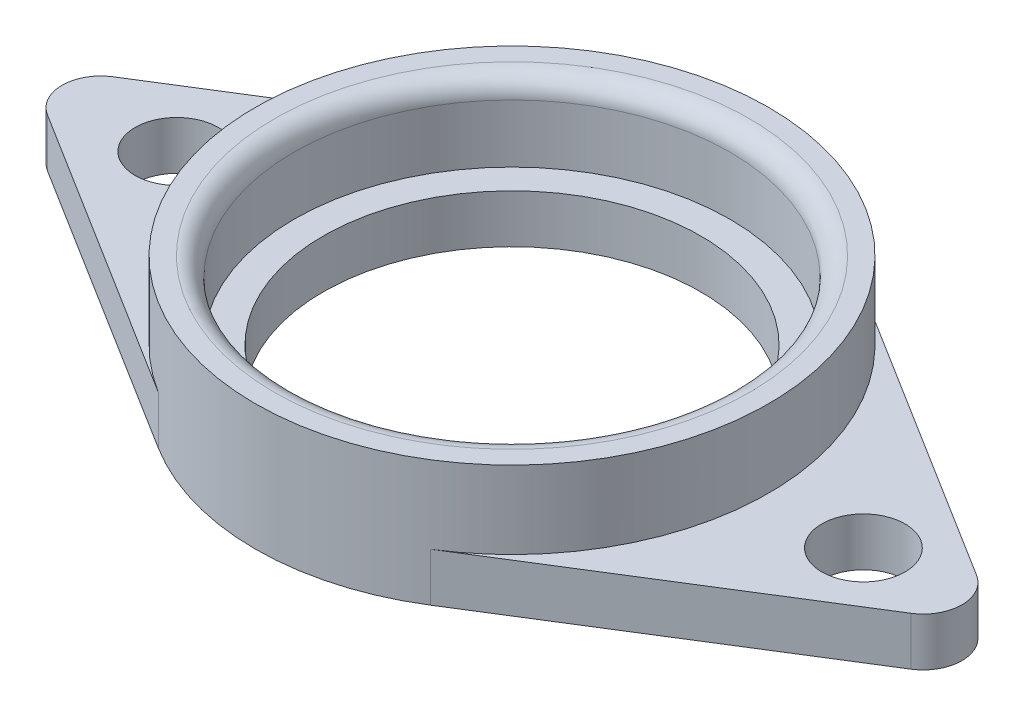
from build123d import *

# Parameters (mm, degrees)
ESQUISSE1_R        = 2.15
ESQUISSE1_R_2      = 9.75
BOSS_EXTRU_1_DEPTH = 2.5
ESQUISSE2_R        = 13.25
ESQUISSE2_R_2      = 11.25
BOSS_EXTRU_2_DEPTH = 4
CONG_1_R           = 1


with BuildPart() as part:
    # Esquisse1 → Boss.-Extru.1 (new body)
    with BuildSketch(Plane(origin=(0, 0, 0), x_dir=(1, 0, 0), z_dir=(0, 1, 0))):
        with BuildLine():
            Line((-7.0225, 11.23596875), (-22.286415094, 1.695995283))
            ThreePointArc((-22.286415094, 1.695995283), (-23.226415094, 0), (-22.286415094, -1.695995283))
            Line((-22.286415094, -1.695995283), (-7.0225, -11.23596875))
            ThreePointArc((-7.0225, -11.23596875), (0, -13.25), (7.0225, -11.23596875))
            Line((7.0225, -11.23596875), (22.286415094, -1.695995283))
            ThreePointArc((22.286415094, -1.695995283), (23.226415094, 0), (22.286415094, 1.695995283))
            Line((22.286415094, 1.695995283), (7.0225, 11.23596875))
            ThreePointArc((7.0225, 11.23596875), (0, 13.25), (-7.0225, 11.23596875))
        make_face()
        with Locations((-17.305198029, 0)):
            Circle(ESQUISSE1_R, mode=Mode.SUBTRACT)
        Circle(ESQUISSE1_R_2, mode=Mode.SUBTRACT)
        with Locations((18.140226284, 0)):
            Circle(ESQUISSE1_R, mode=Mode.SUBTRACT)
    extrude(amount=BOSS_EXTRU_1_DEPTH)

    # Esquisse2 → Boss.-Extru.2 (add)
    with BuildSketch(Plane(origin=(0, 2.5, 0), x_dir=(1, 0, 0), z_dir=(0, 1, 0))):
        Circle(ESQUISSE2_R)
        Circle(ESQUISSE2_R_2, mode=Mode.SUBTRACT)
    extrude(amount=BOSS_EXTRU_2_DEPTH)

    # Congé1
    cong_1_edges = [part.edges().sort_by_distance(p)[0] for p in [
        (-11.25, 6.5, 0),
    ]]
    fillet(cong_1_edges, radius=CONG_1_R)


solid = part.part
